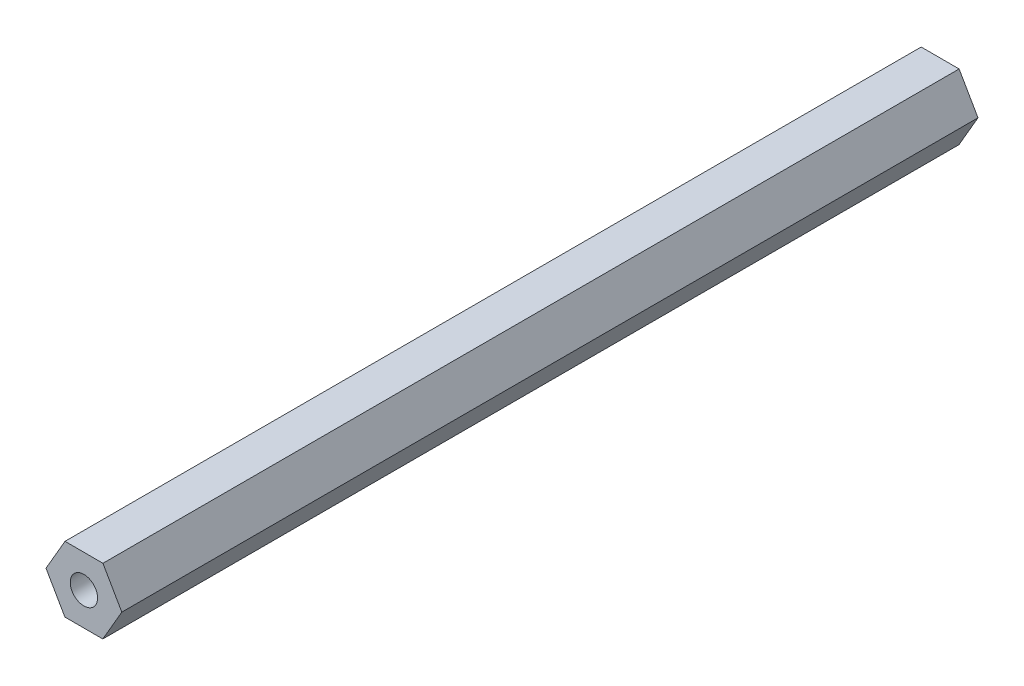
from build123d import *

# Parameters (mm, degrees)
BOSS_EXTRUDE1_DEPTH       = 156.5
M6X1_0_TAPPED_HOLE1_D     = 5
M6X1_0_TAPPED_HOLE1_DEPTH = 17
M6X1_0_TAPPED_HOLE1_TIP   = 1.502151548
M6X1_0_TAPPED_HOLE2_D     = 5
M6X1_0_TAPPED_HOLE2_DEPTH = 17
M6X1_0_TAPPED_HOLE2_TIP   = 1.502151548


with BuildPart() as part:
    # Sketch1 → Boss-Extrude1 (new body)
    with BuildSketch(Plane.XY):
        Polygon((3.452384384, -6.006749709), (6.928190034, -0.013522274), (3.47580565, 5.993227435), (-3.452384384, 6.006749709), (-6.928190034, 0.013522274), (-3.47580565, -5.993227435), align=None)
    extrude(amount=BOSS_EXTRUDE1_DEPTH)

    # M6x1.0 Tapped Hole1
    with Locations(Plane.XY.offset(156.5)):
        with Locations((0, 0)):
            Hole(M6X1_0_TAPPED_HOLE1_D / 2, depth=M6X1_0_TAPPED_HOLE1_DEPTH)
            with Locations((0, 0, -(M6X1_0_TAPPED_HOLE1_DEPTH + M6X1_0_TAPPED_HOLE1_TIP / 2))):  # 118° drill point
                Cone(0, M6X1_0_TAPPED_HOLE1_D / 2, M6X1_0_TAPPED_HOLE1_TIP, mode=Mode.SUBTRACT)

    # M6x1.0 Tapped Hole2
    with Locations(Plane(origin=(0, 0, 0), x_dir=(-1, 0, 0), z_dir=(0, 0, -1))):
        with Locations((0, 0)):
            Hole(M6X1_0_TAPPED_HOLE2_D / 2, depth=M6X1_0_TAPPED_HOLE2_DEPTH)
            with Locations((0, 0, -(M6X1_0_TAPPED_HOLE2_DEPTH + M6X1_0_TAPPED_HOLE2_TIP / 2))):  # 118° drill point
                Cone(0, M6X1_0_TAPPED_HOLE2_D / 2, M6X1_0_TAPPED_HOLE2_TIP, mode=Mode.SUBTRACT)


solid = part.part
